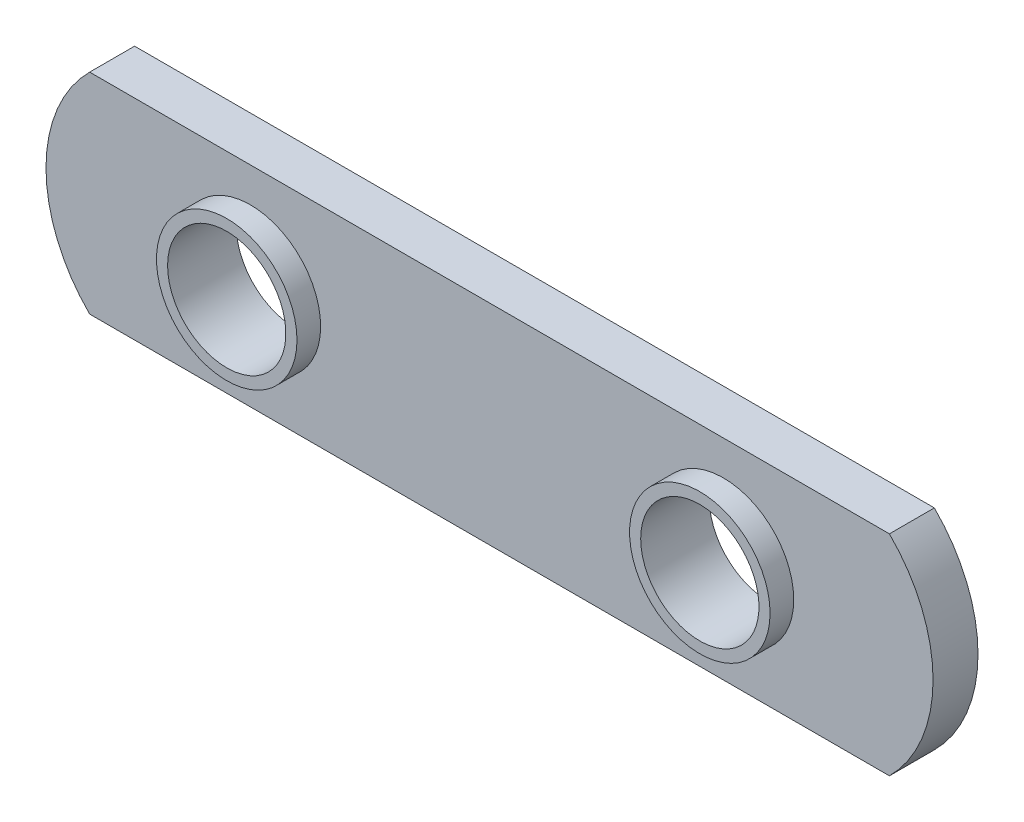
from build123d import *

# Parameters (mm, degrees)
EXTRUDE1_DEPTH     = 2.413
SKETCH4_R          = 3.7719
EXTRUDE3_DEPTH     = 1.27
SKETCH6_R          = 3.175
CUT_EXTRUDE1_DEPTH = 4.683


with BuildPart() as part:
    # Sketch1 → Extrude1 (new body)
    with BuildSketch(Plane.XY):
        with BuildLine():
            Line((101.766590689, 134.097427572), (144.70432984, 134.097427572))
            ThreePointArc((144.70432984, 134.097427572), (147.047960264, 128.471327572), (144.70432984, 122.845227572))
            Line((144.70432984, 122.845227572), (101.766590689, 122.845227572))
            ThreePointArc((101.766590689, 122.845227572), (99.422960264, 128.471327572), (101.766590689, 134.097427572))
        make_face()
    extrude(amount=EXTRUDE1_DEPTH)

    # Sketch4 → Extrude3 (add)
    with BuildSketch(Plane.XY.offset(2.413)):
        with Locations((135.795760264, 128.471327572)):
            Circle(SKETCH4_R)
        with Locations((110.395760264, 128.471327572)):
            Circle(SKETCH4_R)
    extrude(amount=EXTRUDE3_DEPTH)

    # Sketch6 → Cut-Extrude1 (cut, through all)
    with BuildSketch(Plane(origin=(0, 0, 0), x_dir=(-1, 0, 0), z_dir=(0, 0, -1))):
        with Locations((-135.795760264, 128.471327572)):
            Circle(SKETCH6_R)
        with Locations((-110.395760264, 128.471327572)):
            Circle(SKETCH6_R)
    extrude(amount=-CUT_EXTRUDE1_DEPTH, mode=Mode.SUBTRACT)


solid = part.part
